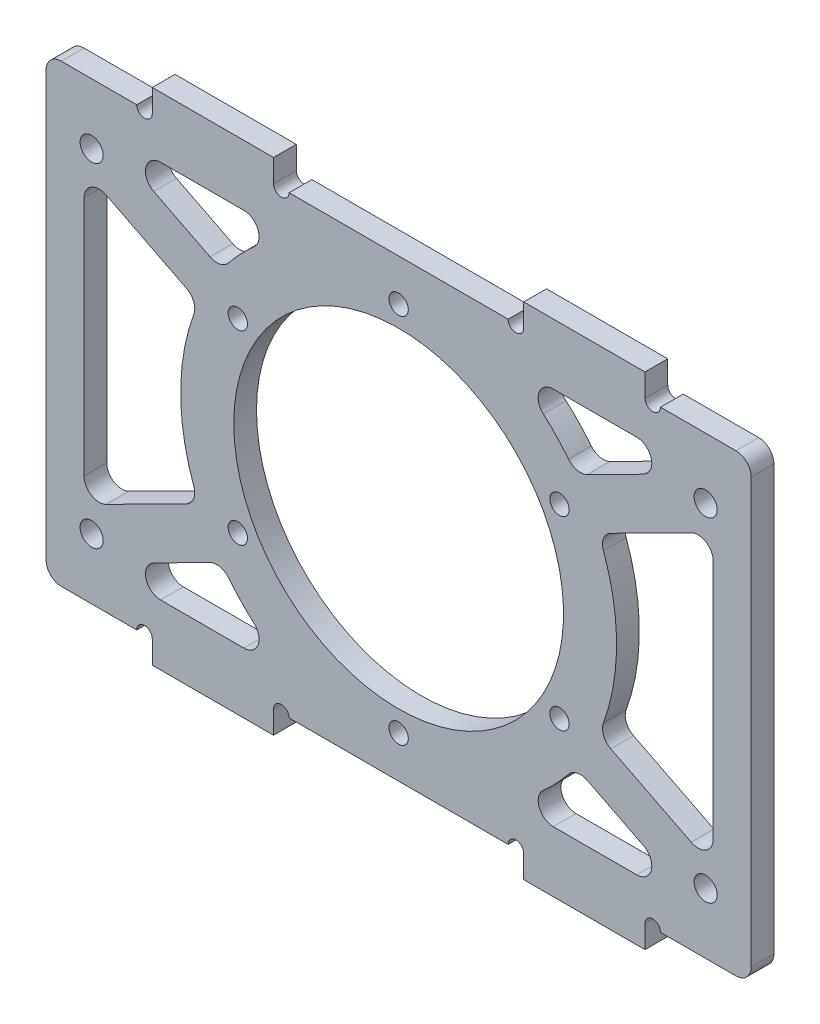
from build123d import *

# Parameters (mm, degrees)
SKETCH_1_W               = 93
SKETCH_1_H               = 60
EXTRUDE_1_DEPTH          = 1.5
SKETCH_2_R               = 21.75
CUT_EXTRUDE_1_DEPTH      = 12
SKETCH_3_R               = 1.275
CUT_EXTRUDE_2_DEPTH      = 12
SKETCH_4_R               = 1.525
CUT_EXTRUDE_3_DEPTH      = 15
CUT_EXTRUDE_5_DEPTH      = 10
FILLET_1_R               = 2
CUT_EXTRUDE_6_DEPTH      = 10
FILLET_2_R               = 2
SKETCH_10_W              = 16
SKETCH_10_H              = 6
EXTRUDE_2_DEPTH          = 3
MIRROR_5_COPY_1_SKETCH_W = 16
MIRROR_5_COPY_1_SKETCH_H = 6
MIRROR_5_COPY_1_DEPTH    = 3
SKETCH_11_R              = 1.025
CUT_EXTRUDE_8_DEPTH      = 3


with BuildPart() as part:
    # 草图1 → 凸台-拉伸1 (new body, symmetric)
    with BuildSketch(Plane.XY):
        Rectangle(SKETCH_1_W, SKETCH_1_H)
    extrude(amount=EXTRUDE_1_DEPTH, both=True)

    # 草图2 → 切除-拉伸1 (cut, symmetric)
    with BuildSketch(Plane.XY.offset(1.5)):
        Circle(SKETCH_2_R)
    extrude(amount=CUT_EXTRUDE_1_DEPTH, both=True, mode=Mode.SUBTRACT)

    # 草图3 → 切除-拉伸2 (cut, symmetric)
    with BuildSketch(Plane.XY.offset(1.5)):
        with Locations((21.217622393, 12.25)):
            Circle(SKETCH_3_R)
        with Locations((21.217622393, -12.25)):
            Circle(SKETCH_3_R)
        with Locations((0, -24.5)):
            Circle(SKETCH_3_R)
        with Locations((-21.217622393, -12.25)):
            Circle(SKETCH_3_R)
        with Locations((-21.217622393, 12.25)):
            Circle(SKETCH_3_R)
        with Locations((0, 24.5)):
            Circle(SKETCH_3_R)
    extrude(amount=CUT_EXTRUDE_2_DEPTH, both=True, mode=Mode.SUBTRACT)

    # 草图4 → 切除-拉伸3 (cut, symmetric)
    with BuildSketch(Plane.XY.offset(1.5)):
        with Locations((40.5, -22)):
            Circle(SKETCH_4_R)
        with Locations((40.5, 22)):
            Circle(SKETCH_4_R)
        with Locations((-40.5, -22)):
            Circle(SKETCH_4_R)
        with Locations((-40.5, 22)):
            Circle(SKETCH_4_R)
    extrude(amount=CUT_EXTRUDE_3_DEPTH, both=True, mode=Mode.SUBTRACT)

    # 草图6 → 切除-拉伸5 (cut)
    with BuildSketch(Plane.XY.offset(1.5)):
        with BuildLine():
            Line((26.355760449, 11.48635674), (41.5, 19.14393604))
            Line((41.5, 19.14393604), (41.5, -19.14393604))
            Line((41.5, -19.14393604), (26.355760449, -11.48635674))
            ThreePointArc((26.355760449, -11.48635674), (28.75, 0), (26.355760449, 11.48635674))
        make_face()
    cut_extrude_5 = extrude(amount=-CUT_EXTRUDE_5_DEPTH, mode=Mode.SUBTRACT)

    # 镜向1: 切除-拉伸5 across plane
    add(cut_extrude_5.mirror(Plane(origin=(0, 0, 0), x_dir=(0, 0, 1), z_dir=(1, 0, 0))), mode=Mode.SUBTRACT)

    # 圆角1
    fillet_1_edges = [part.edges().sort_by_distance(p)[0] for p in [
        (-26.355760449, 11.48635674, 0),
        (-26.355760449, -11.48635674, 0),
        (-41.5, -19.14393604, 0),
        (-41.5, 19.14393604, 0),
        (46.5, -30, 0),
        (-46.5, -30, 0),
        (-46.5, 30, 0),
        (46.5, 30, 0),
        (26.355760449, -11.48635674, 0),
        (26.355760449, 11.48635674, 0),
        (41.5, 19.14393604, 0),
        (41.5, -19.14393604, 0),
    ]]
    fillet(fillet_1_edges, radius=FILLET_1_R)

    # 草图8 → 切除-拉伸6 (cut)
    with BuildSketch(Plane.XY.offset(1.5)):
        with BuildLine():
            Line((14.197270865, 25), (39.784659393, 25))
            Line((39.784659393, 25), (23.393786426, 16.712069192))
            ThreePointArc((23.393786426, 16.712069192), (19.246930829, 21.356922851), (14.197270865, 25))
        make_face()
        with BuildLine():
            Line((39.784659393, -25), (23.393786426, -16.712069192))
            ThreePointArc((23.393786426, -16.712069192), (19.246930829, -21.356922851), (14.197270865, -25))
            Line((14.197270865, -25), (39.784659393, -25))
        make_face()
    cut_extrude_6 = extrude(amount=-CUT_EXTRUDE_6_DEPTH, mode=Mode.SUBTRACT)

    # 镜向2: 切除-拉伸6 across plane
    add(cut_extrude_6.mirror(Plane(origin=(0, 0, 0), x_dir=(0, 0, 1), z_dir=(1, 0, 0))), mode=Mode.SUBTRACT)

    # 圆角2
    fillet_2_edges = [part.edges().sort_by_distance(p)[0] for p in [
        (23.393786426, 16.712069192, 0),
        (14.197270865, 25, 0),
        (39.784659393, 25, 0),
        (14.197270865, -25, 0),
        (23.393786426, -16.712069192, 0),
        (39.784659393, -25, 0),
        (-14.197270865, 25, 0),
        (-23.393786426, 16.712069192, 0),
        (-39.784659393, 25, 0),
        (-23.393786426, -16.712069192, 0),
        (-14.197270865, -25, 0),
        (-39.784659393, -25, 0),
    ]]
    fillet(fillet_2_edges, radius=FILLET_2_R)

    # 草图10 → 凸台-拉伸2 (add)
    with BuildSketch(Plane(origin=(0, 0, -1.5), x_dir=(-1, 0, 0), z_dir=(0, 0, -1))):
        with Locations((-24.5, 30)):
            Rectangle(SKETCH_10_W, SKETCH_10_H)
    extrude_2 = extrude(amount=-EXTRUDE_2_DEPTH)

    # 镜向4: 凸台-拉伸2 across plane
    add(extrude_2.mirror(Plane(origin=(0, 0, 0), x_dir=(0, 0, 1), z_dir=(1, 0, 0))))

    # 镜向5: 凸台-拉伸2 across plane
    add(extrude_2.mirror(Plane.ZX))

    # 镜向5 copy 1 sketch → 镜向5 copy 1 (add)
    with BuildSketch(Plane(origin=(0, 0, -1.5), x_dir=(1, 0, 0), z_dir=(0, 0, -1))):
        with Locations((-24.5, 30)):
            Rectangle(MIRROR_5_COPY_1_SKETCH_W, MIRROR_5_COPY_1_SKETCH_H)
    extrude(amount=-MIRROR_5_COPY_1_DEPTH)

    # 草图11 → 切除-拉伸8 (cut)
    with BuildSketch(Plane.XY.offset(1.5)):
        with Locations((33.525, 30)):
            Circle(SKETCH_11_R)
        with Locations((15.475, 30)):
            Circle(SKETCH_11_R)
        with Locations((-15.475, 30)):
            Circle(SKETCH_11_R)
        with Locations((-33.525, 30)):
            Circle(SKETCH_11_R)
        with Locations((-33.525, -30)):
            Circle(SKETCH_11_R)
        with Locations((-15.475, -30)):
            Circle(SKETCH_11_R)
        with Locations((15.475, -30)):
            Circle(SKETCH_11_R)
        with Locations((33.525, -30)):
            Circle(SKETCH_11_R)
    extrude(amount=-CUT_EXTRUDE_8_DEPTH, mode=Mode.SUBTRACT)


solid = part.part
